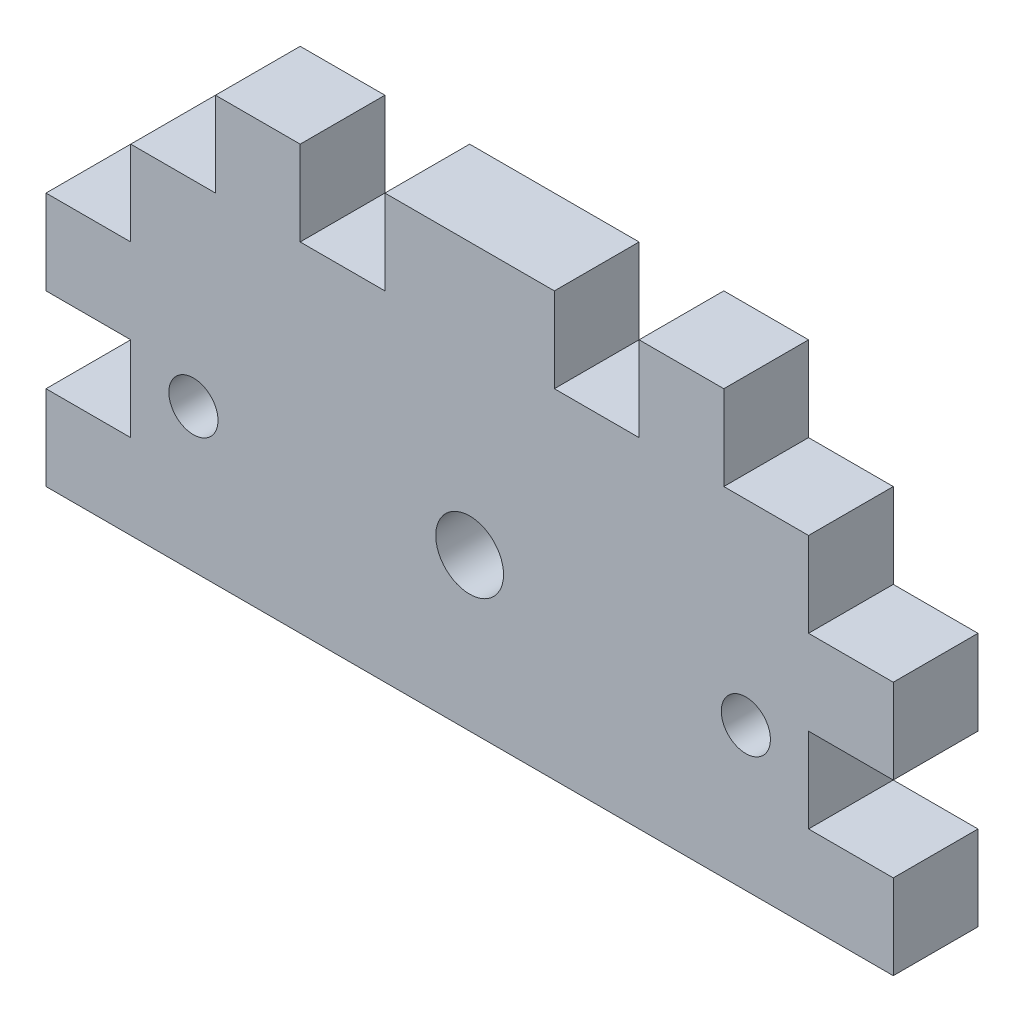
from build123d import *

# Parameters (mm, degrees)
ESQUISSE1_W             = 25
ESQUISSE1_H             = 25
BOSS_EXTRU_1_DEPTH      = 5
ESQUISSE3_R             = 1.45
ESQUISSE3_W             = 5
ESQUISSE3_H             = 5
ENL_V_MAT_EXTRU_1_DEPTH = 5
ESQUISSE5_R             = 2
ENL_V_MAT_EXTRU_2_DEPTH = 10


with BuildPart() as part:
    # Esquisse1 → Boss.-Extru.1 (new body)
    with BuildSketch(Plane.XY):
        with Locations((-53.521610088, -25.407575758)):
            Rectangle(ESQUISSE1_W, ESQUISSE1_H)
    boss_extru_1 = extrude(amount=BOSS_EXTRU_1_DEPTH)

    # Esquisse3 → Enlèv. mat.-Extru.1 (cut)
    with BuildSketch(Plane(origin=(0, 0, 0), x_dir=(-1, 0, 0), z_dir=(0, 0, -1))):
        with Locations((49.721610088, -29.457575758)):
            Circle(ESQUISSE3_R)
        Polygon((46.021610088, -22.907575758), (46.021610088, -17.907575758), (51.021610088, -17.907575758), (51.021610088, -12.907575758), (41.021610088, -12.907575758), (41.021610088, -22.907575758), align=None)
        with Locations((43.521610088, -30.407575758)):
            Rectangle(ESQUISSE3_W, ESQUISSE3_H)
        with Locations((58.521610088, -15.407575758)):
            Rectangle(ESQUISSE3_W, ESQUISSE3_H)
    enl_v_mat_extru_1 = extrude(amount=-ENL_V_MAT_EXTRU_1_DEPTH, mode=Mode.SUBTRACT)

    # Symétrie1: Boss.-Extru.1, Enlèv. mat.-Extru.1 across plane
    add(boss_extru_1.mirror(Plane(origin=(-66.021610088, -12.907575758, 5), x_dir=(0, 0, 1), z_dir=(1, 0, 0))))
    add(enl_v_mat_extru_1.mirror(Plane(origin=(-66.021610088, -12.907575758, 5), x_dir=(0, 0, 1), z_dir=(1, 0, 0))), mode=Mode.SUBTRACT)

    # Esquisse5 → Enlèv. mat.-Extru.2 (cut)
    with BuildSketch(Plane.XY.offset(5)):
        with Locations((-66.021610088, -28.907575758)):
            Circle(ESQUISSE5_R)
    extrude(amount=-ENL_V_MAT_EXTRU_2_DEPTH, mode=Mode.SUBTRACT)


solid = part.part
